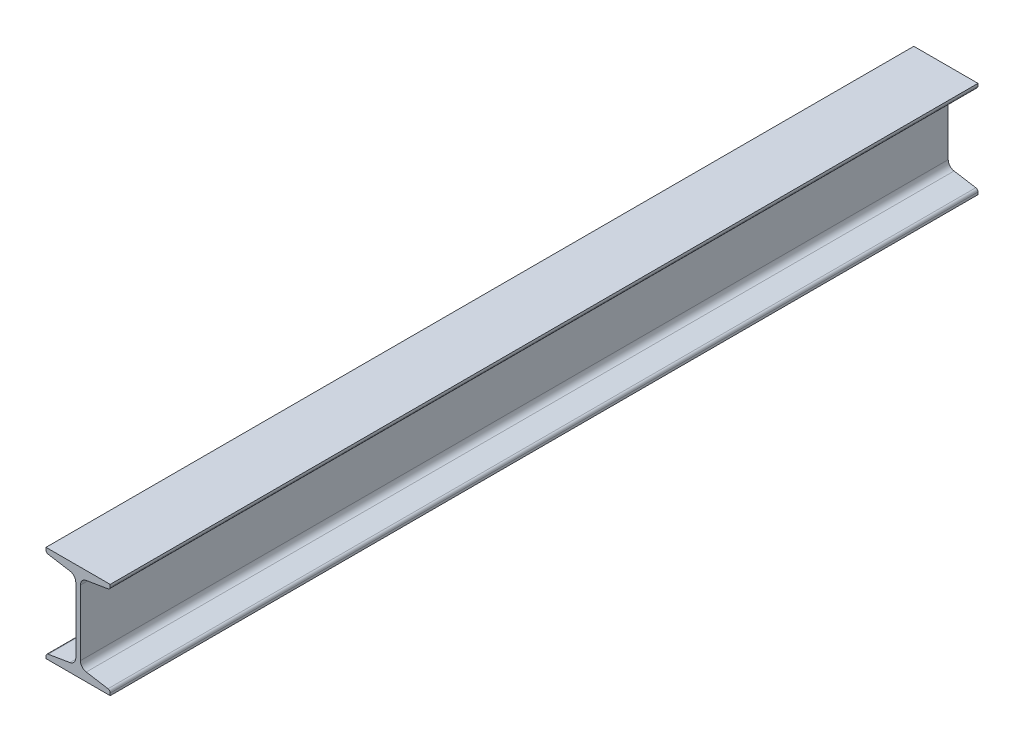
from build123d import *

# Parameters (mm, degrees)
BASESBEAM_DEPTH = 457.2
TOEFILLET_R     = 2.794


with BuildPart() as part:
    # Sketch1 → BaseSbeam (new body, symmetric)
    with BuildSketch(Plane.XY):
        with BuildLine():
            Line((0, 0), (0, 4.82792597))
            Line((0, 4.82792597), (25.214048892, 9.030574012))
            ThreePointArc((25.214048892, 9.030574012), (29.623433353, 11.535173088), (31.369, 16.296337329))
            Line((31.369, 16.296337329), (31.369, 85.303662671))
            ThreePointArc((31.369, 85.303662671), (29.623433353, 90.064826912), (25.214048892, 92.569425988))
            Line((25.214048892, 92.569425988), (0, 96.77207403))
            Line((0, 96.77207403), (0, 101.6))
            Line((0, 101.6), (67.6402, 101.6))
            Line((67.6402, 101.6), (67.6402, 96.77207403))
            Line((67.6402, 96.77207403), (42.426151108, 92.569425988))
            ThreePointArc((42.426151108, 92.569425988), (38.016766647, 90.064826912), (36.2712, 85.303662671))
            Line((36.2712, 85.303662671), (36.2712, 16.296337329))
            ThreePointArc((36.2712, 16.296337329), (38.016766647, 11.535173088), (42.426151108, 9.030574012))
            Line((42.426151108, 9.030574012), (67.6402, 4.82792597))
            Line((67.6402, 4.82792597), (67.6402, 0))
            Line((67.6402, 0), (0, 0))
        make_face()
    extrude(amount=BASESBEAM_DEPTH, both=True)

    # ToeFillet
    toefillet_edges = [part.edges().sort_by_distance(p)[0] for p in [
        (67.6402, 4.82792597, 0),
        (67.6402, 96.77207403, 0),
        (0, 96.77207403, 0),
        (0, 4.82792597, 0),
    ]]
    fillet(toefillet_edges, radius=TOEFILLET_R)


solid = part.part
